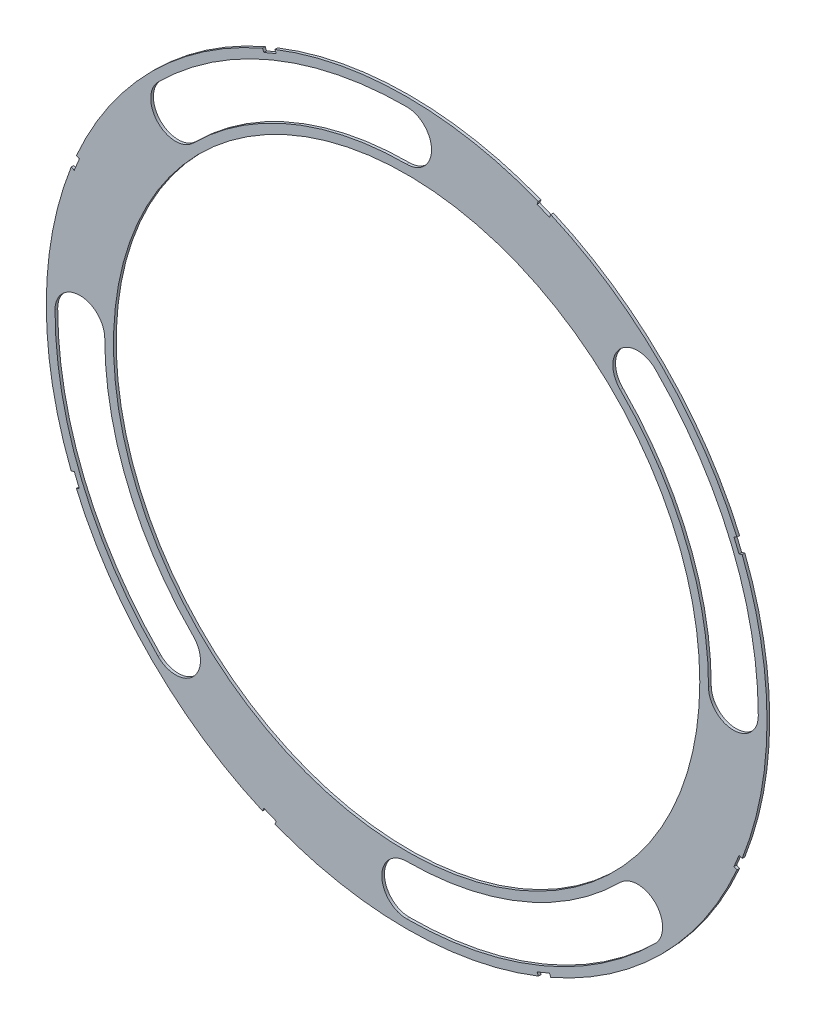
from build123d import *

# Parameters (mm, degrees)
SKETCH4_R           = 68.072
BOSS_EXTRUDE2_DEPTH = 0.508
SKETCH5_R           = 55.372
CUT_EXTRUDE5_DEPTH  = 1.508
CUT_EXTRUDE6_DEPTH  = 1.508
CUT_EXTRUDE11_DEPTH = 1.508


with BuildPart() as part:
    # Sketch4 → Boss-Extrude2 (new body)
    with BuildSketch(Plane.XY):
        Circle(SKETCH4_R)
    extrude(amount=BOSS_EXTRUDE2_DEPTH)

    # Sketch5 → Cut-Extrude5 (cut, through all)
    with BuildSketch(Plane.XY.offset(0.508)):
        Circle(SKETCH5_R)
    extrude(amount=-CUT_EXTRUDE5_DEPTH, mode=Mode.SUBTRACT)

    # Sketch6 → Cut-Extrude6 (cut, through all)
    with BuildSketch(Plane.XY.offset(0.508)):
        with BuildLine():
            ThreePointArc((46.966739661, 46.966739366), (40.321349994, 46.966739524), (40.32135011, 40.321349857))
            ThreePointArc((40.32135011, 40.321349857), (52.682382823, 21.821756782), (57.023, -1.08e-06))
            ThreePointArc((57.023, -1.08e-06), (61.721999911, -4.699), (66.421, -1.258e-06))
            ThreePointArc((66.421, -1.258e-06), (61.36500271, 25.418215583), (46.966739661, 46.966739366))
        make_face()
        with BuildLine():
            ThreePointArc((46.966739366, -46.966739661), (46.966739524, -40.321349994), (40.321349857, -40.32135011))
            ThreePointArc((40.321349857, -40.32135011), (21.821756782, -52.682382823), (-1.08e-06, -57.023))
            ThreePointArc((-1.08e-06, -57.023), (-4.699, -61.721999911), (-1.258e-06, -66.421))
            ThreePointArc((-1.258e-06, -66.421), (25.418215583, -61.36500271), (46.966739366, -46.966739661))
        make_face()
        with BuildLine():
            ThreePointArc((-46.966739661, -46.966739366), (-40.321349994, -46.966739524), (-40.32135011, -40.321349857))
            ThreePointArc((-40.32135011, -40.321349857), (-52.682382823, -21.821756782), (-57.023, 1.08e-06))
            ThreePointArc((-57.023, 1.08e-06), (-61.721999911, 4.699), (-66.421, 1.258e-06))
            ThreePointArc((-66.421, 1.258e-06), (-61.36500271, -25.418215583), (-46.966739661, -46.966739366))
        make_face()
        with BuildLine():
            ThreePointArc((-46.966739366, 46.966739661), (-46.966739524, 40.321349994), (-40.321349857, 40.32135011))
            ThreePointArc((-40.321349857, 40.32135011), (-21.821756782, 52.682382823), (1.08e-06, 57.023))
            ThreePointArc((1.08e-06, 57.023), (4.699, 61.721999911), (1.258e-06, 66.421))
            ThreePointArc((1.258e-06, 66.421), (-25.418215583, 61.36500271), (-46.966739366, 46.966739661))
        make_face()
    extrude(amount=-CUT_EXTRUDE6_DEPTH, mode=Mode.SUBTRACT)

    # Sketch8 → Cut-Extrude11 (cut, through all)
    with BuildSketch(Plane.XY.offset(0.508)):
        Polygon((63.962998999, 25.119703581), (62.990983081, 27.466357594), (61.817656075, 26.980349635), (62.789671993, 24.633695622), align=None)
        Polygon((-25.119703581, 63.962998999), (-27.466357594, 62.990983081), (-26.980349635, 61.817656075), (-24.633695622, 62.789671993), align=None)
        Polygon((-62.990983081, 27.466357594), (-63.962998999, 25.119703581), (-62.789671993, 24.633695622), (-61.817656075, 26.980349635), align=None)
        Polygon((-63.962998999, -25.119703581), (-62.990983081, -27.466357594), (-61.817656075, -26.980349635), (-62.789671993, -24.633695622), align=None)
        Polygon((-27.466357594, -62.990983081), (-25.119703581, -63.962998999), (-24.633695622, -62.789671993), (-26.980349635, -61.817656075), align=None)
        Polygon((25.119703581, -63.962998999), (27.466357594, -62.990983081), (26.980349635, -61.817656075), (24.633695622, -62.789671993), align=None)
        Polygon((62.990983081, -27.466357594), (63.962998999, -25.119703581), (62.789671993, -24.633695622), (61.817656075, -26.980349635), align=None)
        Polygon((27.466357594, 62.990983081), (25.119703581, 63.962998999), (24.633695622, 62.789671993), (26.980349635, 61.817656075), align=None)
    extrude(amount=-CUT_EXTRUDE11_DEPTH, mode=Mode.SUBTRACT)


solid = part.part
